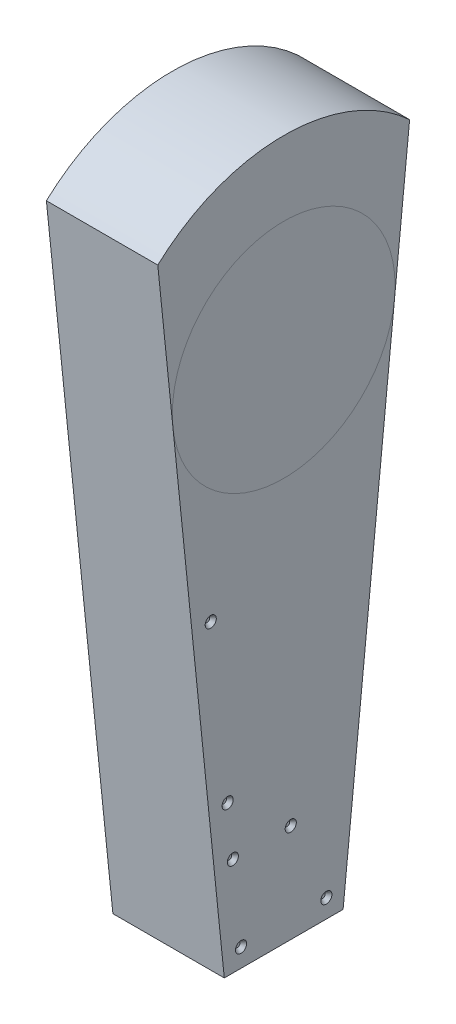
from build123d import *

# Parameters (mm, degrees)
SALIENTE_EXTRUIR1_DEPTH = 76.2
CROQUIS4_R              = 3.81
CORTAR_EXTRUIR1_DEPTH   = 2.54
CORTAR_EXTRUIR1_TAPER   = 39
CROQUIS5_R              = 3.81
CORTAR_EXTRUIR2_DEPTH   = 2.54
CORTAR_EXTRUIR2_TAPER   = 39


with BuildPart() as part:
    # Croquis1 → Saliente-Extruir1 (new body)
    with BuildSketch(Plane(origin=(0, 0, 0), x_dir=(0, 0, -1), z_dir=(1, 0, 0))):
        with BuildLine():
            Line((-40.64, -351.79000001), (-86.135923686, 93.325251946))
            ThreePointArc((-86.135923686, 93.325251946), (0, 127), (86.135923686, 93.325251946))
            Line((86.135923686, 93.325251946), (40.64, -351.79000001))
            Line((40.64, -351.79000001), (-40.64, -351.79000001))
        make_face()
    extrude(amount=SALIENTE_EXTRUIR1_DEPTH)

    # Croquis4 → Cortar-Extruir1 (cut)
    with BuildSketch(Plane(origin=(76.2, 0, 0), x_dir=(0, 0, -1), z_dir=(1, 0, 0))):
        with Locations((-49.917099877, -136.126844727)):
            Circle(CROQUIS4_R)
        with Locations((-38.362373799, -249.174001321)):
            Circle(CROQUIS4_R)
        with Locations((-34.768096531, -284.339077712)):
            Circle(CROQUIS4_R)
        with Locations((-29.171919425, -339.09000001)):
            Circle(CROQUIS4_R)
        with Locations((29.171919425, -339.09000001)):
            Circle(CROQUIS4_R)
        with Locations((4.819460737, -284.339077712)):
            Circle(CROQUIS4_R)
    extrude(amount=-CORTAR_EXTRUIR1_DEPTH, taper=CORTAR_EXTRUIR1_TAPER, mode=Mode.SUBTRACT)

    # Croquis5 → Cortar-Extruir2 (cut)
    with BuildSketch(Plane.ZY):
        with Locations((-12.556850651, -339.09000001)):
            Circle(CROQUIS5_R)
        with Locations((12.556850651, -339.09000001)):
            Circle(CROQUIS5_R)
        with Locations((-34.182100121, -290.072249352)):
            Circle(CROQUIS5_R)
        with Locations((-48.265473167, -152.285748198)):
            Circle(CROQUIS5_R)
        with Locations((-69.751939629, 57.929874619)):
            Circle(CROQUIS5_R)
        with Locations((-48.265473167, 103.609527072)):
            Circle(CROQUIS5_R)
        with Locations((48.265473167, 103.609527072)):
            Circle(CROQUIS5_R)
        with Locations((69.751939629, 57.929874619)):
            Circle(CROQUIS5_R)
        with Locations((48.265473167, -152.285748198)):
            Circle(CROQUIS5_R)
    extrude(amount=-CORTAR_EXTRUIR2_DEPTH, taper=CORTAR_EXTRUIR2_TAPER, mode=Mode.SUBTRACT)


solid = part.part
